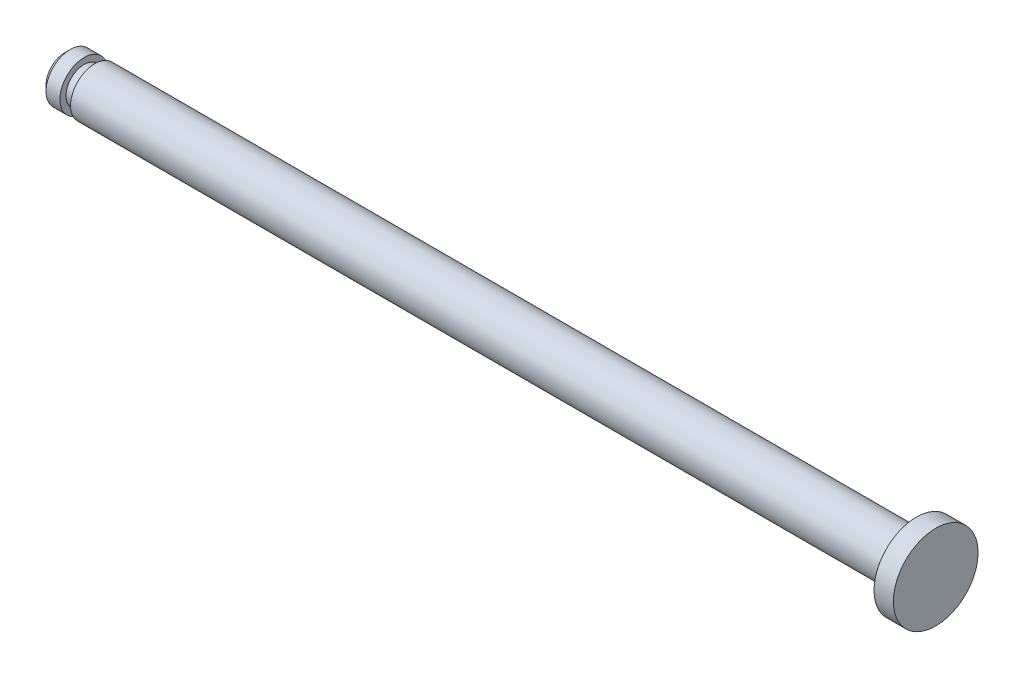
from build123d import *


with BuildPart() as part:
    # Esquisse3 → Révolution1 (revolve)
    with BuildSketch(Plane.XY, mode=Mode.PRIVATE) as r_volution1_sk:
        Polygon((-0.8, 1), (-0.8, 1.75), (0, 1.75), (0, 0), (-36, 0), (-36, 0.775275826), (-35.775275826, 1), (-35.2, 1), (-35.2, 0.75), (-34.76, 0.75), (-34.76, 1), align=None)
    revolve(r_volution1_sk.sketch.rotate(Axis((-40.281486239, 0, 0), (1, 0, 0)), 90), axis=Axis((-40.281486239, 0, 0), (1, 0, 0)))  # turned: the seam where the file's is


solid = part.part
